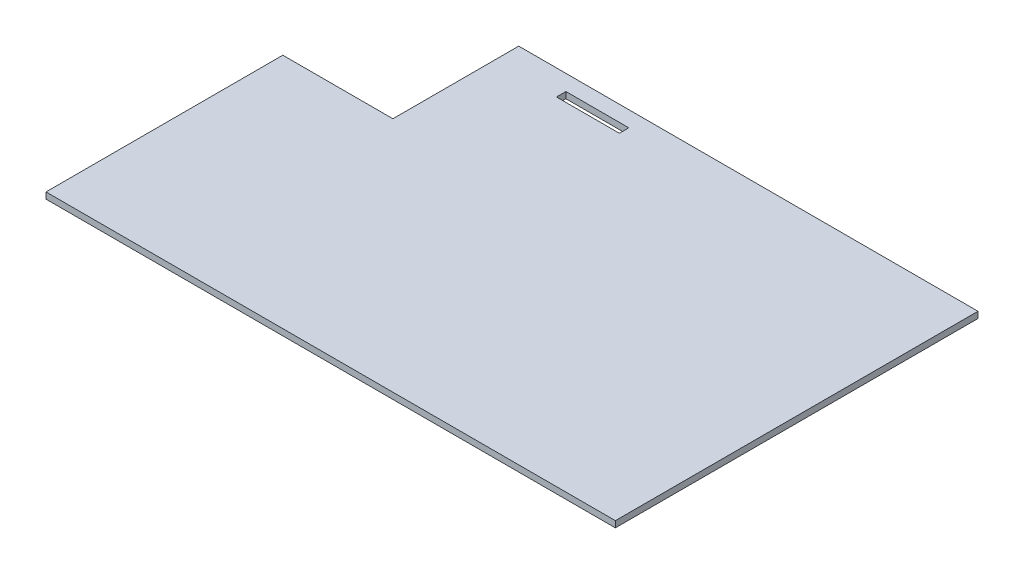
from build123d import *

# Parameters (mm, degrees)
SKETCH1_W           = 25.4
SKETCH1_H           = 3.81
BOSS_EXTRUDE1_DEPTH = 2.54


with BuildPart() as part:
    # Sketch1 → Boss-Extrude1 (new body)
    with BuildSketch(Plane(origin=(0, 0, 0), x_dir=(1, 0, 0), z_dir=(0, 1, 0))):
        Polygon((0, -50.8), (44.45, -50.8), (44.45, 0), (229.87, 0), (229.87, -146.4056), (0, -146.4056), align=None)
        with Locations((82.55, -8.255)):
            Rectangle(SKETCH1_W, SKETCH1_H, mode=Mode.SUBTRACT)
    extrude(amount=BOSS_EXTRUDE1_DEPTH)


solid = part.part
